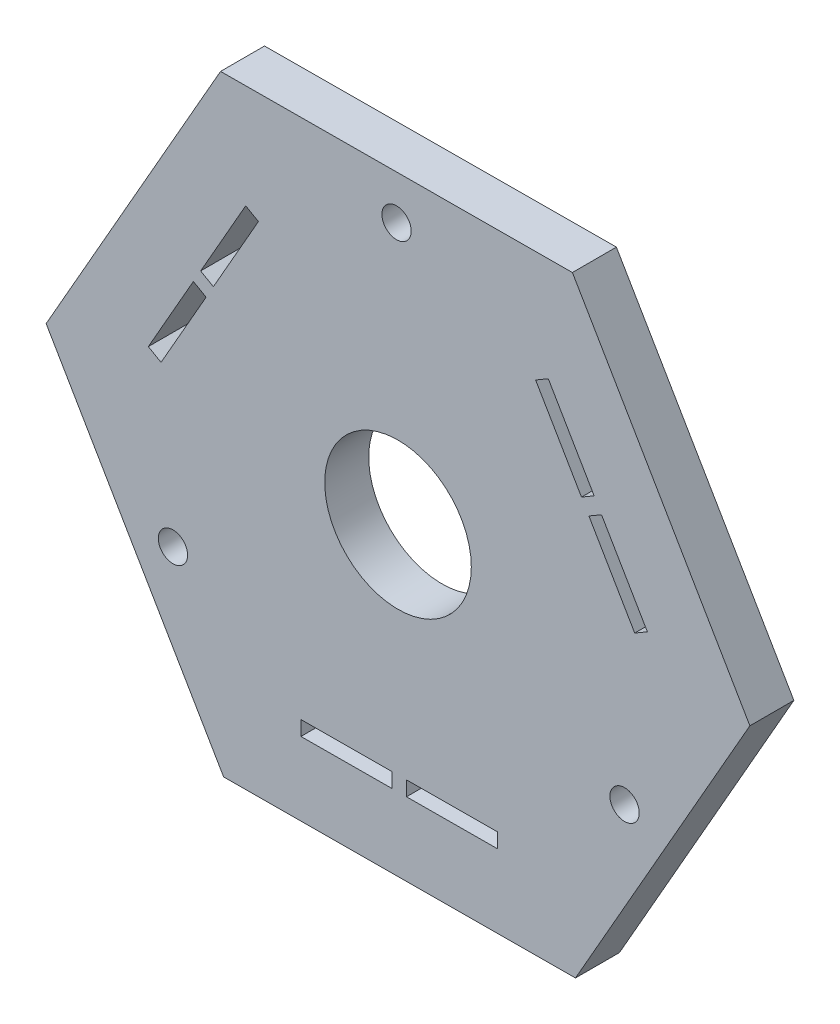
from build123d import *

# Parameters (mm, degrees)
EXTRUDE_1_DEPTH     = 3
CUT_EXTRUDE_1_DEPTH = 3
SKETCH_3_R          = 5
CUT_EXTRUDE_2_DEPTH = 3
SKETCH_6_R          = 1
CUT_EXTRUDE_3_DEPTH = 3


with BuildPart() as part:
    # 草图1 → 凸台-拉伸1 (new body)
    with BuildSketch(Plane.XY):
        Polygon((11.895283312, 20.845067899), (-12.104716688, 20.724151483), (-24, -0.120916416), (-11.895283312, -20.845067899), (12.104716688, -20.724151483), (24, 0.120916416), align=None)
    extrude(amount=EXTRUDE_1_DEPTH)

    # 草图2 → 切除-拉伸1 (cut)
    with BuildSketch(Plane.XY.offset(3)):
        Polygon((10.250974371, 13.746627049), (9.387479018, 13.242270255), (12.514491143, 7.888599068), (13.377986495, 8.392955863), align=None)
        Polygon((13.018847937, 7.025103716), (13.88234329, 7.52946051), (17.009355414, 2.175789323), (16.145860061, 1.671432529), align=None)
        Polygon((6.779441055, -15.750917743), (6.774402935, -14.750930435), (0.574481622, -14.782166779), (0.579519742, -15.782154088), align=None)
        Polygon((-0.425505687, -14.787204899), (-0.420467566, -15.787192208), (-6.62038888, -15.818428552), (-6.625427, -14.818441244), align=None)
        Polygon((-17.030415426, 2.004290694), (-16.161881954, 1.50866018), (-13.088972765, 6.893567711), (-13.957506238, 7.389198225), align=None)
        Polygon((-12.59334225, 7.762101184), (-13.461875723, 8.257731698), (-10.388966534, 13.642639229), (-9.520433062, 13.147008715), align=None)
    extrude(amount=-CUT_EXTRUDE_1_DEPTH, mode=Mode.SUBTRACT)

    # 草图3 → 切除-拉伸2 (cut)
    with BuildSketch(Plane.XY.offset(3)):
        Circle(SKETCH_3_R)
    extrude(amount=-CUT_EXTRUDE_2_DEPTH, mode=Mode.SUBTRACT)

    # 草图6 → 切除-拉伸3 (cut)
    with BuildSketch(Plane.XY.offset(3)):
        with Locations((-0.100452801, 17.784593098)):
            Circle(SKETCH_6_R)
        with Locations((15.45213582, -8.805301872)):
            Circle(SKETCH_6_R)
        with Locations((-15.351683019, -8.979291227)):
            Circle(SKETCH_6_R)
    extrude(amount=-CUT_EXTRUDE_3_DEPTH, mode=Mode.SUBTRACT)


solid = part.part
